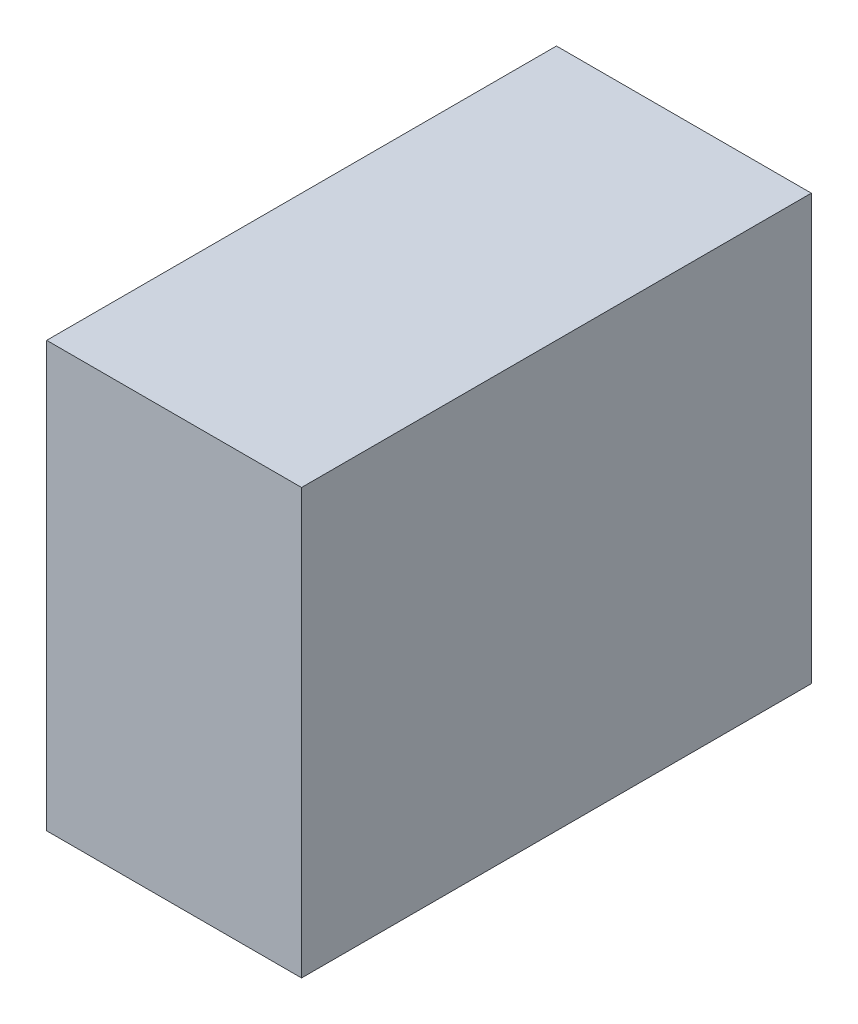
from build123d import *

# Parameters (mm, degrees)
SKETCH1_W           = 38.1
SKETCH1_H           = 63.5
BOSS_EXTRUDE1_DEPTH = 76.2


with BuildPart() as part:
    # Sketch1 → Boss-Extrude1 (new body)
    with BuildSketch(Plane.XY):
        Rectangle(SKETCH1_W, SKETCH1_H)
    extrude(amount=BOSS_EXTRUDE1_DEPTH)


solid = part.part
